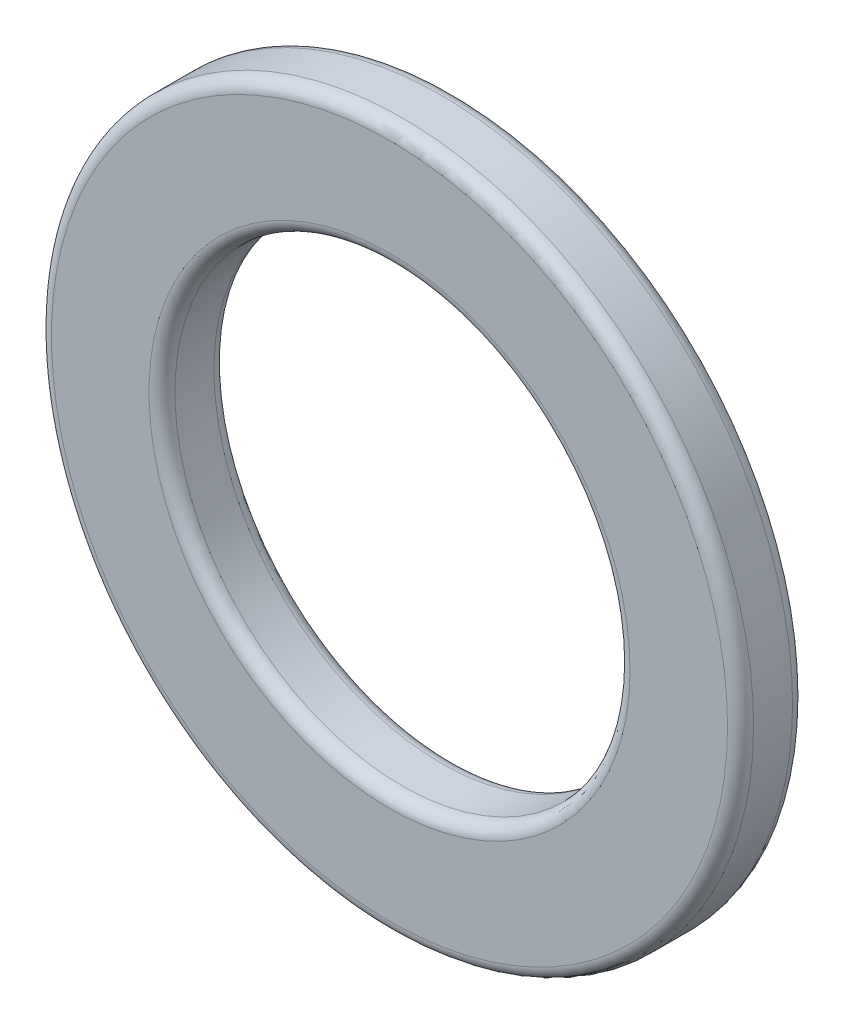
from build123d import *

# Parameters (mm, degrees)
SKETCH1_R           = 5.4
SKETCH1_R_2         = 3.5
BOSS_EXTRUDE1_DEPTH = 1
FILLET1_R           = 0.2


with BuildPart() as part:
    # Sketch1 → Boss-Extrude1 (new body)
    with BuildSketch(Plane.XY):
        Circle(SKETCH1_R)
        Circle(SKETCH1_R_2, mode=Mode.SUBTRACT)
    extrude(amount=BOSS_EXTRUDE1_DEPTH)

    # Fillet1
    fillet1_edges = [part.edges().sort_by_distance(p)[0] for p in [
        (-3.5, 0, 0),
        (-3.5, 0, 1),
        (-5.4, 0, 0),
        (-5.4, 0, 1),
    ]]
    fillet(fillet1_edges, radius=FILLET1_R)


solid = part.part
